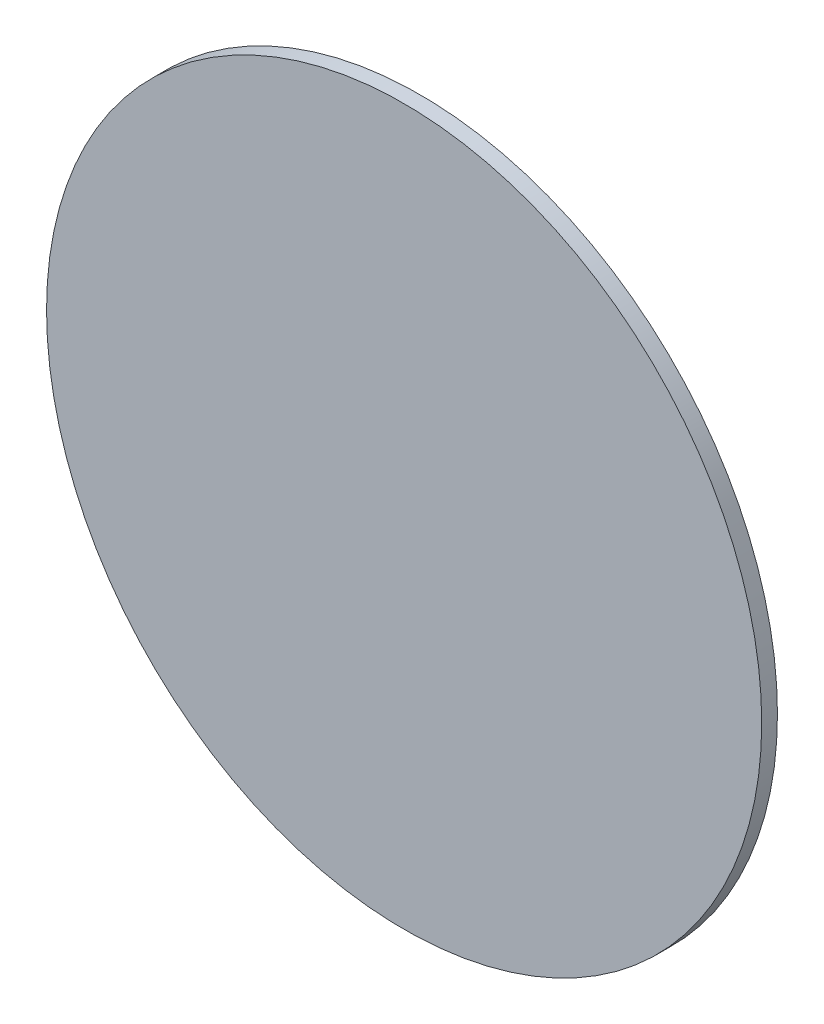
from build123d import *

# Parameters (mm, degrees)
SKETCH_1_R      = 25
EXTRUDE_1_DEPTH = 1.1


with BuildPart() as part:
    # 草图1 → 凸台-拉伸1 (new body)
    with BuildSketch(Plane.XY):
        Circle(SKETCH_1_R)
    extrude(amount=EXTRUDE_1_DEPTH)


solid = part.part
